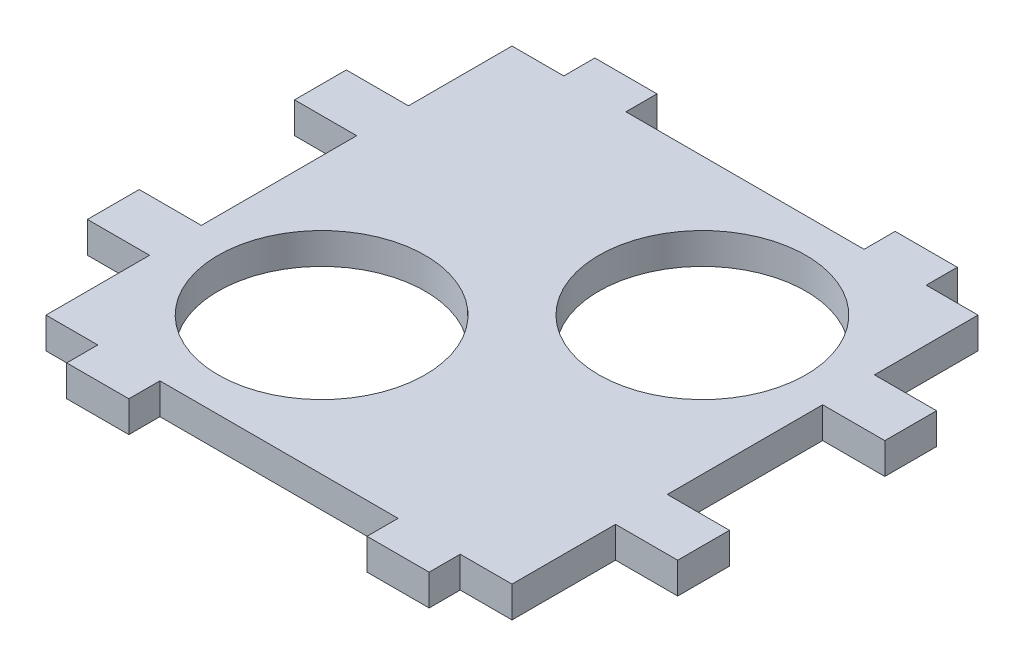
from build123d import *

# Parameters (mm, degrees)
SALIENTE_EXTRUIR1_DEPTH = 3
CROQUIS1_4_W            = 6
CROQUIS1_4_H            = 5
SALIENTE_EXTRUIR2_DEPTH = 3
CROQUIS2_R              = 10
CORTAR_EXTRUIR3_DEPTH   = 39.360135558
CROQUIS1_5_W            = 6
CROQUIS1_5_H            = 5
SALIENTE_EXTRUIR3_DEPTH = 3


with BuildPart() as part:
    # Croquis1 → Saliente-Extruir1 (new body)
    with BuildSketch(Plane(origin=(0, 0, 0), x_dir=(1, 0, 0), z_dir=(0, 1, 0))):
        Polygon((-17.5, 22.5), (-22.5, 22.5), (-22.5, -22.5), (-17.5, -22.5), (-17.5, -25.5), (-11.5, -25.5), (-11.5, -22.5), (11.5, -22.5), (11.5, -25.5), (17.5, -25.5), (17.5, -22.5), (22.5, -22.5), (22.5, 22.5), (17.5, 22.5), (17.5, 25.5), (11.5, 25.5), (11.5, 22.5), (-11.5, 22.5), (-11.5, 25.5), (-17.5, 25.5), align=None)
    extrude(amount=SALIENTE_EXTRUIR1_DEPTH)

    # Croquis1_4 → Saliente-Extruir2 (add)
    with BuildSketch(Plane(origin=(0, 0, 0), x_dir=(1, 0, 0), z_dir=(0, 1, 0))):
        with Locations((-25.5, -10)):
            Rectangle(CROQUIS1_4_W, CROQUIS1_4_H)
        with Locations((25.5, -10)):
            Rectangle(CROQUIS1_4_W, CROQUIS1_4_H)
    extrude(amount=SALIENTE_EXTRUIR2_DEPTH)

    # Croquis2 → Cortar-Extruir3 (cut, through all)
    with BuildSketch(Plane(origin=(0, 3, 0), x_dir=(1, 0, 0), z_dir=(0, 1, 0))):
        with Locations((-9.192388155, -9.192388155)):
            Circle(CROQUIS2_R)
        with Locations((9.192388155, 9.192388155)):
            Circle(CROQUIS2_R)
    extrude(amount=-CORTAR_EXTRUIR3_DEPTH, mode=Mode.SUBTRACT)

    # Croquis1_5 → Saliente-Extruir3 (add)
    with BuildSketch(Plane(origin=(0, 0, 0), x_dir=(1, 0, 0), z_dir=(0, 1, 0))):
        with Locations((-25.5, 10)):
            Rectangle(CROQUIS1_5_W, CROQUIS1_5_H)
        with Locations((25.5, 10)):
            Rectangle(CROQUIS1_5_W, CROQUIS1_5_H)
    extrude(amount=SALIENTE_EXTRUIR3_DEPTH)


solid = part.part
